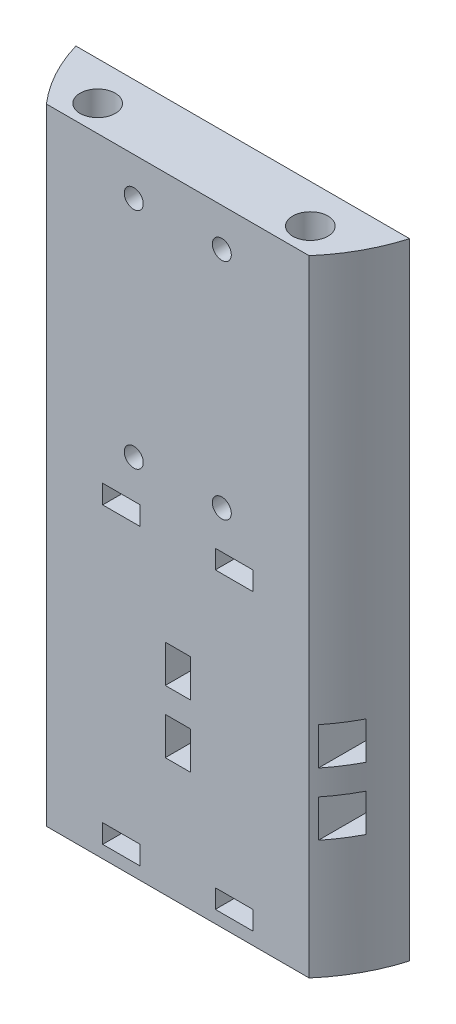
from build123d import *

# Parameters (mm, degrees)
BOSS_EXTRUDE1_DEPTH       = 127
SKETCH10_W                = 62.671930198
SKETCH10_H                = 63.5
CUT_EXTRUDE1_DEPTH        = 2.54
F_1_4_CLEARANCE_HOLE1_D   = 7.14248
F_8_CLEARANCE_HOLE1_D     = 3.8608
SKETCH19_W                = 5.08
SKETCH19_H                = 7.62
SKETCH19_W_2              = 3.81
SKETCH19_W_3              = 7.62
SKETCH19_H_2              = 3.81
CUT_EXTRUDE3_DEPTH        = 14.188436542
F_8_CLEARANCE_HOLE2_D     = 3.8608
F_8_CLEARANCE_HOLE2_DEPTH = 3.81


with BuildPart() as part:
    # Sketch1 → Boss-Extrude1 (new body)
    with BuildSketch(Plane(origin=(0, 0, 0), x_dir=(1, 0, 0), z_dir=(0, 1, 0))):
        with BuildLine():
            Line((-33.875965099, -9.946488053), (33.875965099, -9.946488053))
            ThreePointArc((33.875965099, -9.946488053), (30.982853114, -16.928569016), (26.67, -23.134924595))
            Line((26.67, -23.134924595), (-26.67, -23.134924595))
            ThreePointArc((-26.67, -23.134924595), (-30.982853114, -16.928569016), (-33.875965099, -9.946488053))
        make_face()
    extrude(amount=BOSS_EXTRUDE1_DEPTH)

    # Sketch10 → Cut-Extrude1 (cut)
    with BuildSketch(Plane(origin=(0, 0, 9.946488053), x_dir=(-1, 0, 0), z_dir=(0, 0, -1))):
        with Locations((0, 34.29)):
            Rectangle(SKETCH10_W, SKETCH10_H)
    extrude(amount=-CUT_EXTRUDE1_DEPTH, mode=Mode.SUBTRACT)

    # 1/4 Clearance Hole1 (through all)
    with Locations(Plane(origin=(0, 127, 0), x_dir=(1, 0, 0), z_dir=(0, 1, 0))):
        with Locations((-21.59, -17.810706324), (21.59, -17.810706324)):
            Hole(F_1_4_CLEARANCE_HOLE1_D / 2)

    # #8 Clearance Hole1 (through all)
    with Locations(Plane(origin=(0, 0, 9.946488053), x_dir=(-1, 0, 0), z_dir=(0, 0, -1))):
        with Locations((-8.93698255, 119.253), (-8.93698255, 73.787), (8.93698255, 73.787), (8.93698255, 119.253)):
            Hole(F_8_CLEARANCE_HOLE1_D / 2)

    # Sketch19 → Cut-Extrude3 (cut, through all)
    with BuildSketch(Plane(origin=(0, 0, 9.946488053), x_dir=(-1, 0, 0), z_dir=(0, 0, -1))):
        with Locations((0, 40.64)):
            Rectangle(SKETCH19_W, SKETCH19_H)
        with Locations((0, 27.94)):
            Rectangle(SKETCH19_W, SKETCH19_H)
        with Locations((29.430965099, 40.64)):
            Rectangle(SKETCH19_W_2, SKETCH19_H)
        with Locations((-11.43, 64.135)):
            Rectangle(SKETCH19_W_3, SKETCH19_H_2)
        with Locations((11.43, 64.135)):
            Rectangle(SKETCH19_W_3, SKETCH19_H_2)
        with Locations((-11.43, 4.445)):
            Rectangle(SKETCH19_W_3, SKETCH19_H_2)
        with Locations((11.43, 4.445)):
            Rectangle(SKETCH19_W_3, SKETCH19_H_2)
        with Locations((-29.430965099, 40.64)):
            Rectangle(SKETCH19_W_2, SKETCH19_H)
        with Locations((29.430965099, 27.94)):
            Rectangle(SKETCH19_W_2, SKETCH19_H)
        with Locations((-29.430965099, 27.94)):
            Rectangle(SKETCH19_W_2, SKETCH19_H)
    extrude(amount=-CUT_EXTRUDE3_DEPTH, mode=Mode.SUBTRACT)

    # #8 Clearance Hole2
    with Locations(Plane(origin=(0, 0, 9.946488053), x_dir=(-1, 0, 0), z_dir=(0, 0, -1))):
        with Locations((-24.93898255, 119.253), (-24.93898255, 73.787), (24.93898255, 73.787), (24.93898255, 119.253)):
            Hole(F_8_CLEARANCE_HOLE2_D / 2, depth=F_8_CLEARANCE_HOLE2_DEPTH)


solid = part.part
